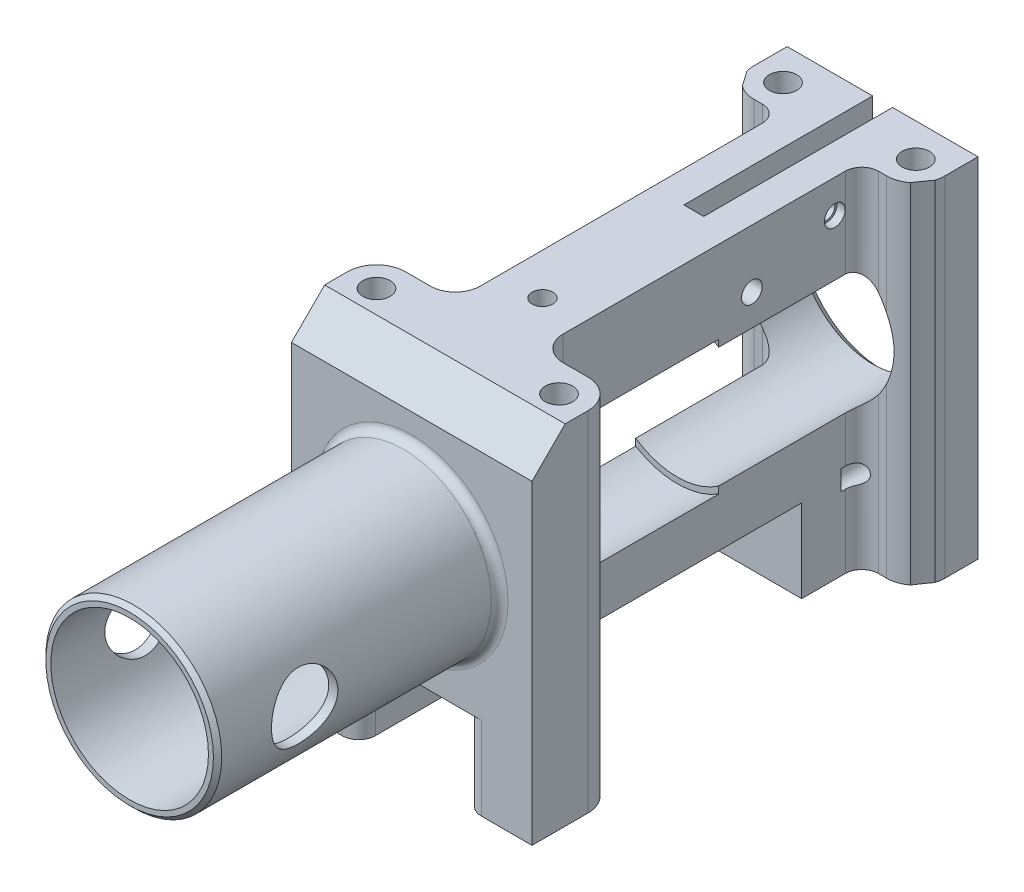
from build123d import *

# Parameters (mm, degrees)
SKETCH_1_W                = 40
SKETCH_1_H                = 36
SKETCH_1_R                = 8.8
EXTRUDE_1_DEPTH           = 67
SKETCH_2_W                = 2.4
SKETCH_2_H                = 19
CUT_EXTRUDE_1_DEPTH       = 20
SKETCH_3_R                = 1.05
CUT_EXTRUDE_2_DEPTH       = 41
SKETCH_5_W                = 2
SKETCH_5_H                = 12
CUT_EXTRUDE_5_DEPTH       = 41
SKETCH_6_R                = 31.5
CUT_EXTRUDE_6_DEPTH       = 37
SKETCH_7_R                = 9.5
CUT_EXTRUDE_7_DEPTH       = 32
SKETCH_8_R                = 10.6
SKETCH_8_R_2              = 9.5
EXTRUDE_2_DEPTH           = 34
FILLET_1_R                = 1
SKETCH_9_W                = 2.4
SKETCH_9_H                = 14
CUT_EXTRUDE_8_DEPTH       = 20
SKETCH_12_R               = 1
SKETCH_12_R_2             = 1.25
CUT_EXTRUDE_9_DEPTH       = 30
CUT_EXTRUDE_START         = -4
SKETCH_13_R               = 1.25
CUT_EXTRUDE_10_DEPTH      = 60
CUT_EXTRUDE_START_2       = 4
SKETCH_13_2_R             = 1.25
CUT_EXTRUDE_11_DEPTH      = 60
SKETCH_16_W               = 5
SKETCH_16_H               = 8
CUT_EXTRUDE_14_DEPTH      = 37.0000001
EXTRUDE_5_DEPTH           = 6
CUT_EXTRUDE_START_3       = 6
SKETCH_17_R               = 1.65
SKETCH_17_R_2             = 1.25
CUT_EXTRUDE_15_DEPTH      = 10
CUT_EXTRUDE_START_4       = -36
SKETCH_17_2_R             = 1.65
SKETCH_17_2_R_2           = 1.25
CUT_EXTRUDE_16_DEPTH      = 8
SKETCH_18_W               = 3.083874254
SKETCH_18_H               = 3.083874254
CUT_EXTRUDE_17_DEPTH      = 43
SKETCH_22_R               = 4
CUT_EXTRUDE_22_DEPTH      = 21.0000001
CUT_EXTRUDE_22_DEPTH_BACK = 21.0000001
CHAMFER_1_SIZE            = 4
CUT_EXTRUDE_25_DEPTH      = 43
CHAMFER_2_SIZE            = 1.2
SKETCH_29_R               = 1.2
CUT_EXTRUDE_26_DEPTH      = 10
CHAMFER_3_SIZE            = 0.5
CUT_EXTRUDE_27_DEPTH      = 19.0000001
CUT_EXTRUDE_27_DEPTH_BACK = 25
CUT_EXTRUDE_28_DEPTH      = 4


with BuildPart() as part:
    # Sketch 1 → Extrude 1 (new body)
    with BuildSketch(Plane.XY):
        Rectangle(SKETCH_1_W, SKETCH_1_H)
        Circle(SKETCH_1_R, mode=Mode.SUBTRACT)
    extrude(amount=EXTRUDE_1_DEPTH)

    # Sketch 11 → Cut-Revolve 1 (revolve, cut)
    with BuildSketch(Plane(origin=(0, 0, 0), x_dir=(0, 0, -1), z_dir=(1, 0, 0))):
        Polygon((0, 0), (0, -10.5), (-10.5, 0), align=None)
    revolve(axis=Axis((0, 0, 0), (0, 0, -1)), mode=Mode.SUBTRACT)

    # Sketch 2 → Cut-Extrude 1 (cut)
    with BuildSketch(Plane(origin=(0, 18, 0), x_dir=(1, 0, 0), z_dir=(0, 1, 0))):
        with Locations((0, -9.5)):
            Rectangle(SKETCH_2_W, SKETCH_2_H)
    extrude(amount=-CUT_EXTRUDE_1_DEPTH, mode=Mode.SUBTRACT)

    # Sketch 3 → Cut-Extrude 2 (cut, through all)
    with BuildSketch(Plane(origin=(20, 0, 0), x_dir=(0, 0, -1), z_dir=(1, 0, 0))):
        with Locations((-3, 15)):
            Circle(SKETCH_3_R)
        with Locations((-3, -15)):
            Circle(SKETCH_3_R)
    extrude(amount=-CUT_EXTRUDE_2_DEPTH, mode=Mode.SUBTRACT)

    # Sketch 5 → Cut-Extrude 5 (cut, through all)
    with BuildSketch(Plane.ZY.offset(20)):
        with Locations((1, 0)):
            Rectangle(SKETCH_5_W, SKETCH_5_H)
    extrude(amount=-CUT_EXTRUDE_5_DEPTH, mode=Mode.SUBTRACT)

    # Sketch 6 → Cut-Extrude 6 (cut, through all)
    with BuildSketch(Plane(origin=(0, 18, 0), x_dir=(1, 0, 0), z_dir=(0, 1, 0))):
        with Locations((36.5, -34.247448714)):
            Circle(SKETCH_6_R)
        with Locations((-36.5, -34.247448714)):
            Circle(SKETCH_6_R)
    extrude(amount=-CUT_EXTRUDE_6_DEPTH, mode=Mode.SUBTRACT)

    # Sketch 7 → Cut-Extrude 7 (cut)
    with BuildSketch(Plane.XY.offset(67)):
        Circle(SKETCH_7_R)
    extrude(amount=-CUT_EXTRUDE_7_DEPTH, mode=Mode.SUBTRACT)

    # Sketch 8 → Extrude 2 (add)
    with BuildSketch(Plane.XY.offset(67)):
        Circle(SKETCH_8_R)
        Circle(SKETCH_8_R_2, mode=Mode.SUBTRACT)
    extrude(amount=EXTRUDE_2_DEPTH)

    # Fillet 1
    fillet_1_edges = [part.edges().sort_by_distance(p)[0] for p in [
        (-10.6, 0, 67),
    ]]
    fillet(fillet_1_edges, radius=FILLET_1_R)

    # Sketch 9 → Cut-Extrude 8 (cut)
    with BuildSketch(Plane(origin=(0, 18, 0), x_dir=(1, 0, 0), z_dir=(0, 1, 0))):
        with Locations((0, -26)):
            Rectangle(SKETCH_9_W, SKETCH_9_H)
    extrude(amount=-CUT_EXTRUDE_8_DEPTH, mode=Mode.SUBTRACT)

    # Sketch 12 → Cut-Extrude 9 (cut, symmetric)
    with BuildSketch(Plane(origin=(0, 0, 0), x_dir=(0, 0, -1), z_dir=(1, 0, 0))):
        with Locations((-21, 14)):
            Circle(SKETCH_12_R)
        with Locations((-31, 11)):
            Circle(SKETCH_12_R_2)
    extrude(amount=CUT_EXTRUDE_9_DEPTH, both=True, mode=Mode.SUBTRACT)

    # Sketch 13 → Cut-Extrude 10 (cut)
    with BuildSketch(Plane(origin=(0, 0, 0), x_dir=(0, 0, -1), z_dir=(1, 0, 0)).offset(CUT_EXTRUDE_START)):
        with Locations((-21, 14)):
            Circle(SKETCH_13_R)
    extrude(amount=-CUT_EXTRUDE_10_DEPTH, mode=Mode.SUBTRACT)

    # Sketch 13_2 → Cut-Extrude 11 (cut)
    with BuildSketch(Plane(origin=(0, 0, 0), x_dir=(0, 0, -1), z_dir=(1, 0, 0)).offset(CUT_EXTRUDE_START_2)):
        with Locations((-21, 14)):
            Circle(SKETCH_13_2_R)
    extrude(amount=CUT_EXTRUDE_11_DEPTH, mode=Mode.SUBTRACT)

    # Sketch 16 → Cut-Extrude 14 (cut, through all)
    with BuildSketch(Plane(origin=(0, 18, 0), x_dir=(1, 0, 0), z_dir=(0, 1, 0))):
        with Locations((-17.5, -4)):
            Rectangle(SKETCH_16_W, SKETCH_16_H)
        with Locations((17.5, -4)):
            Rectangle(SKETCH_16_W, SKETCH_16_H)
    extrude(amount=-CUT_EXTRUDE_14_DEPTH, mode=Mode.SUBTRACT)

    # Sketch 28 → Extrude 5 (add)
    with BuildSketch(Plane.XZ.offset(18)):
        with BuildLine():
            Line((-20, 67), (-8.387964328, 67))
            ThreePointArc((-8.387964328, 67), (-6.973750766, 66.414213562), (-6.387964328, 65))
            Line((-6.387964328, 65), (-6.387964328, 57))
            ThreePointArc((-6.387964328, 57), (-6.973750766, 55.585786438), (-8.387964328, 55))
            Line((-8.387964328, 55), (-12.802286711, 55))
            ThreePointArc((-12.802286711, 55), (-16.17252002, 58.310772625), (-20, 61.080264444))
            Line((-20, 61.080264444), (-20, 67))
        make_face()
        with BuildLine():
            Line((20, 67), (20, 61.080264444))
            ThreePointArc((20, 61.080264444), (16.17252002, 58.310772625), (12.802286711, 55))
            Line((12.802286711, 55), (8.387964328, 55))
            ThreePointArc((8.387964328, 55), (6.973750766, 55.585786438), (6.387964328, 57))
            Line((6.387964328, 57), (6.387964328, 65))
            ThreePointArc((6.387964328, 65), (6.973750766, 66.414213562), (8.387964328, 67))
            Line((8.387964328, 67), (20, 67))
        make_face()
        with BuildLine():
            Line((16.2, 8), (3.2, 8))
            Line((3.2, 8), (-3.2, 8))
            Line((-3.2, 8), (-16.2, 8))
            Line((-16.2, 8), (-16.2, 10.160937966))
            ThreePointArc((-16.2, 10.160937966), (-10.224673634, 16.87340991), (-6.387964328, 25))
            Line((-6.387964328, 25), (-3.2, 25))
            Line((-3.2, 25), (3.2, 25))
            Line((3.2, 25), (6.387964328, 25))
            ThreePointArc((6.387964328, 25), (10.224673634, 16.87340991), (16.2, 10.160937966))
            Line((16.2, 10.160937966), (16.2, 8))
        make_face()
    extrude(amount=EXTRUDE_5_DEPTH)

    # Sketch 17 → Cut-Extrude 15 (cut)
    with BuildSketch(Plane.XZ.offset(18).offset(CUT_EXTRUDE_START_3)):
        with Locations((-8, 14.24744871)):
            Circle(SKETCH_17_R)
        with Locations((8, 14.24744871)):
            Circle(SKETCH_17_R)
        with Locations((11, 60.24744871)):
            Circle(SKETCH_17_R)
        with Locations((-11, 60.24744871)):
            Circle(SKETCH_17_R)
        with Locations((0, 51.24744871)):
            Circle(SKETCH_17_R_2)
    extrude(amount=-CUT_EXTRUDE_15_DEPTH, mode=Mode.SUBTRACT)

    # Sketch 17_2 → Cut-Extrude 16 (cut)
    with BuildSketch(Plane.XZ.offset(18).offset(CUT_EXTRUDE_START_4)):
        with Locations((-8, 14.24744871)):
            Circle(SKETCH_17_2_R)
        with Locations((8, 14.24744871)):
            Circle(SKETCH_17_2_R)
        with Locations((11, 60.24744871)):
            Circle(SKETCH_17_2_R)
        with Locations((-11, 60.24744871)):
            Circle(SKETCH_17_2_R)
        with Locations((0, 51.24744871)):
            Circle(SKETCH_17_2_R_2)
    extrude(amount=CUT_EXTRUDE_16_DEPTH, mode=Mode.SUBTRACT)

    # Sketch 18 → Cut-Extrude 17 (cut, through all)
    with BuildSketch(Plane(origin=(0, 18, 0), x_dir=(1, 0, 0), z_dir=(0, 1, 0))):
        with Locations((17.541937127, -9.541937127)):
            Rectangle(SKETCH_18_W, SKETCH_18_H)
        with Locations((-17.541937127, -9.541937127)):
            Rectangle(SKETCH_18_W, SKETCH_18_H)
    extrude(amount=-CUT_EXTRUDE_17_DEPTH, mode=Mode.SUBTRACT)

    # Sketch 22 → Cut-Extrude 22 (cut, two sides)
    with BuildSketch(Plane(origin=(0, 0, 0), x_dir=(0, 0, -1), z_dir=(1, 0, 0))) as cut_extrude_22_sk:
        with Locations((-90.5, 0)):
            Circle(SKETCH_22_R)
    extrude(amount=CUT_EXTRUDE_22_DEPTH, mode=Mode.SUBTRACT)
    extrude(cut_extrude_22_sk.sketch, amount=-CUT_EXTRUDE_22_DEPTH_BACK, mode=Mode.SUBTRACT)

    # Chamfer 1
    chamfer_1_edges = [part.edges().sort_by_distance(p)[0] for p in [
        (0, -18, 67),
        (0, 18, 67),
    ]]
    chamfer(chamfer_1_edges, length=CHAMFER_1_SIZE)

    # Sketch 25 → Cut-Extrude 25 (cut, through all)
    with BuildSketch(Plane(origin=(0, 18, 0), x_dir=(1, 0, 0), z_dir=(0, 1, 0))):
        Polygon((-25, 0), (25, 0), (25, -20), (15, -20), (15, -10.247448714), (-15, -10.247448714), (-15, -20), (-25, -20), align=None)
    extrude(amount=-CUT_EXTRUDE_25_DEPTH, mode=Mode.SUBTRACT)

    # Chamfer 2
    chamfer_2_edges = [part.edges().sort_by_distance(p)[0] for p in [
        (-5.782732918, -6.633249581, 10.247448714),
    ]]
    chamfer(chamfer_2_edges, length=CHAMFER_2_SIZE)

    # Sketch 29 → Cut-Extrude 26 (cut)
    with BuildSketch(Plane(origin=(0, 0, 10.247448714), x_dir=(-1, 0, 0), z_dir=(0, 0, -1))):
        with Locations((5, -14)):
            Circle(SKETCH_29_R)
        with Locations((-5, -14)):
            Circle(SKETCH_29_R)
    extrude(amount=-CUT_EXTRUDE_26_DEPTH, mode=Mode.SUBTRACT)

    # Chamfer 3
    chamfer_3_edges = [part.edges().sort_by_distance(p)[0] for p in [
        (-10.6, 0, 101),
    ]]
    chamfer(chamfer_3_edges, length=CHAMFER_3_SIZE)

    # Sketch 33 → Cut-Extrude 27 (cut, two sides)
    with BuildSketch(Plane(origin=(0, 0, 0), x_dir=(1, 0, 0), z_dir=(0, 1, 0))) as cut_extrude_27_sk:
        with BuildLine():
            Line((-14.5, -60.24744871), (-14.5, -67))
            Line((-14.5, -67), (-20, -67))
            Line((-20, -67), (-20, -34.247448714))
            Line((-20, -34.247448714), (-20, -10.247448714))
            Line((-20, -10.247448714), (-11.5, -10.247448714))
            Line((-11.5, -10.247448714), (-11.5, -14.24744871))
            ThreePointArc((-11.5, -14.24744871), (-10.474873734, -16.722322444), (-8, -17.74744871))
            Line((-8, -17.74744871), (-7, -17.74744871))
            ThreePointArc((-7, -17.74744871), (-5.585786438, -18.333235148), (-5, -19.74744871))
            Line((-5, -19.74744871), (-5, -34.247448714))
            Line((-5, -34.247448714), (-5, -53.74744871))
            ThreePointArc((-5, -53.74744871), (-5.878679656, -55.868769054), (-8, -56.74744871))
            Line((-8, -56.74744871), (-11, -56.74744871))
            ThreePointArc((-11, -56.74744871), (-13.474873734, -57.772574976), (-14.5, -60.24744871))
        make_face()
        with BuildLine():
            Line((11.5, -14.24744871), (11.5, -10.247448714))
            Line((11.5, -10.247448714), (20, -10.247448714))
            Line((20, -10.247448714), (20, -34.247448714))
            Line((20, -34.247448714), (20, -67))
            Line((20, -67), (14.5, -67))
            Line((14.5, -67), (14.5, -60.24744871))
            ThreePointArc((14.5, -60.24744871), (13.474873734, -57.772574976), (11, -56.74744871))
            Line((11, -56.74744871), (8, -56.74744871))
            ThreePointArc((8, -56.74744871), (5.878679656, -55.868769054), (5, -53.74744871))
            Line((5, -53.74744871), (5, -34.247448714))
            Line((5, -34.247448714), (5, -19.74744871))
            ThreePointArc((5, -19.74744871), (5.585786438, -18.333235148), (7, -17.74744871))
            Line((7, -17.74744871), (8, -17.74744871))
            ThreePointArc((8, -17.74744871), (10.474873734, -16.722322444), (11.5, -14.24744871))
        make_face()
    extrude(amount=CUT_EXTRUDE_27_DEPTH, mode=Mode.SUBTRACT)
    extrude(cut_extrude_27_sk.sketch, amount=-CUT_EXTRUDE_27_DEPTH_BACK, mode=Mode.SUBTRACT)

    # Sketch 34 → Cut-Extrude 28 (cut)
    with BuildSketch(Plane.XZ.offset(18)):
        with BuildLine():
            Line((-5, 53.74744871), (-5, 25))
            Line((-5, 25), (5, 25))
            Line((5, 25), (5, 53.74744871))
            ThreePointArc((5, 53.74744871), (5.401462067, 55.246648701), (6.498400408, 56.34460074))
            ThreePointArc((6.498400408, 56.34460074), (6.41576659, 56.667680757), (6.387964328, 57))
            Line((6.387964328, 57), (6.387964328, 63))
            Line((6.387964328, 63), (6.387964328, 65))
            ThreePointArc((6.387964328, 65), (6.973750766, 66.414213562), (8.387964328, 67))
            Line((8.387964328, 67), (-8.387964328, 67))
            ThreePointArc((-8.387964328, 67), (-6.973750766, 66.414213562), (-6.387964328, 65))
            Line((-6.387964328, 65), (-6.387964328, 63))
            Line((-6.387964328, 63), (-6.387964328, 57))
            ThreePointArc((-6.387964328, 57), (-6.41576659, 56.667680757), (-6.498400408, 56.34460074))
            ThreePointArc((-6.498400408, 56.34460074), (-5.401462067, 55.246648701), (-5, 53.74744871))
        make_face()
    extrude(amount=-CUT_EXTRUDE_28_DEPTH, mode=Mode.SUBTRACT)


solid = part.part
